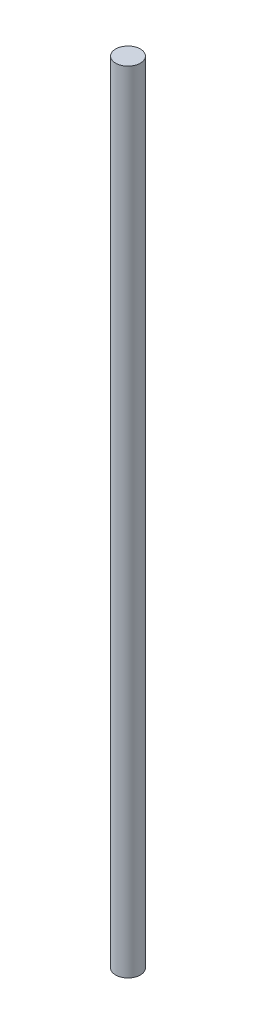
from build123d import *

# Parameters (mm, degrees)
SKETCH1_R           = 4.7625
BOSS_EXTRUDE1_DEPTH = 304.8


with BuildPart() as part:
    # Sketch1 → Boss-Extrude1 (new body)
    with BuildSketch(Plane(origin=(0, 0, 0), x_dir=(1, 0, 0), z_dir=(0, 1, 0))):
        Circle(SKETCH1_R)
    extrude(amount=BOSS_EXTRUDE1_DEPTH)


solid = part.part
